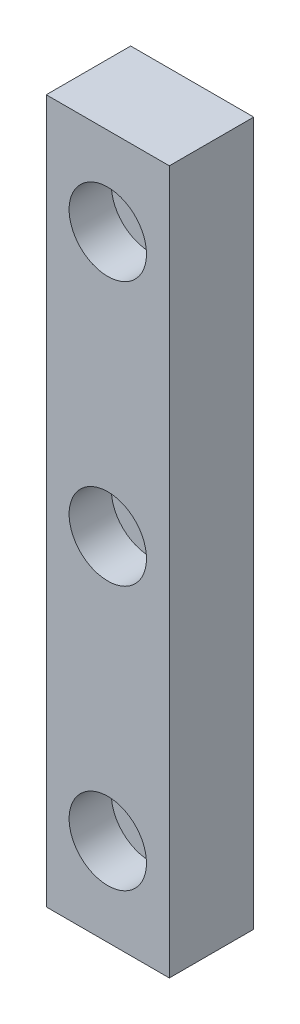
from build123d import *

# Parameters (mm, degrees)
SKETCH_1_W                   = 7
SKETCH_1_H                   = 40
EXTRUDE_1_DEPTH              = 4.8
HOLE_WIZARD_M2_1_D           = 2.4
HOLE_WIZARD_M2_1_DEPTH       = 10.1
HOLE_WIZARD_M2_1_CBORE_D     = 4.4
HOLE_WIZARD_M2_1_CBORE_DEPTH = 2.4
HOLE_WIZARD_M2_1_TIP         = 0.721032743


with BuildPart() as part:
    # 草图1 → 凸台-拉伸1 (new body)
    with BuildSketch(Plane.XY):
        with Locations((3.5, 20)):
            Rectangle(SKETCH_1_W, SKETCH_1_H)
    extrude(amount=EXTRUDE_1_DEPTH)

    # M2 六角凹头螺钉的柱形沉头孔1
    with Locations(Plane.XY.offset(4.8)):
        with Locations((3.5, 35), (3.5, 20), (3.5, 5)):
            CounterBoreHole(HOLE_WIZARD_M2_1_D / 2, HOLE_WIZARD_M2_1_CBORE_D / 2, HOLE_WIZARD_M2_1_CBORE_DEPTH, depth=HOLE_WIZARD_M2_1_DEPTH)
            with Locations((0, 0, -(HOLE_WIZARD_M2_1_DEPTH + HOLE_WIZARD_M2_1_TIP / 2))):  # 118° drill point
                Cone(0, HOLE_WIZARD_M2_1_D / 2, HOLE_WIZARD_M2_1_TIP, mode=Mode.SUBTRACT)


solid = part.part
